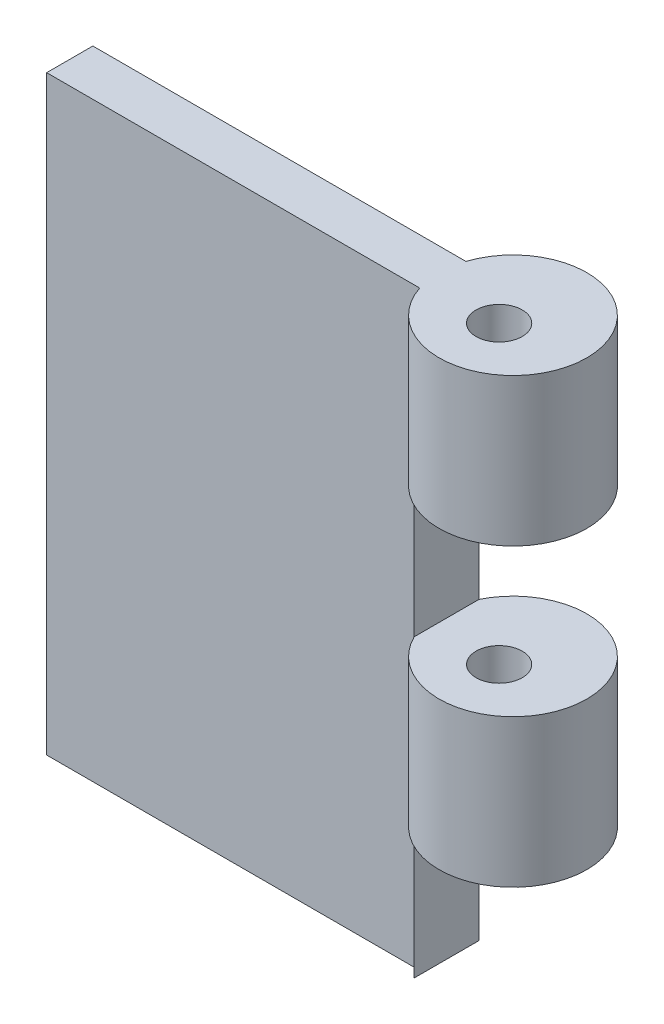
from build123d import *

# Parameters (mm, degrees)
SKETCH1_W                      = 15.24
SKETCH1_H                      = 20.32
BOSS_EXTRUDE1_DEPTH            = 1.5875
SKETCH2_W                      = 2.54
SKETCH2_H                      = 20.32
F_1_16_0_0625_DIAMETER_HOLE1_D = 1.5875
SKETCH10_W                     = 5.245479694
SKETCH10_H                     = 5.08
CUT_EXTRUDE1_DEPTH             = 6.35


with BuildPart() as part:
    # Sketch1 → Boss-Extrude1 (new body)
    with BuildSketch(Plane.XY):
        Rectangle(SKETCH1_W, SKETCH1_H)
    extrude(amount=BOSS_EXTRUDE1_DEPTH)

    # Sketch2 → Revolve-Thin1 (revolve)
    with BuildSketch(Plane(origin=(7.62, 0, 0), x_dir=(0, 0, -1), z_dir=(1, 0, 0))):
        with Locations((-2.06375, 0)):
            Rectangle(SKETCH2_W, SKETCH2_H)
    revolve(axis=Axis((7.62, -10.16, 0.79375), (0, 1, 0)))

    # 1/16 (0.0625) Diameter Hole1 (through all)
    with Locations(Plane(origin=(0, 10.16, 0), x_dir=(1, 0, 0), z_dir=(0, 1, 0))):
        with Locations((7.62, -1.27)):
            Hole(F_1_16_0_0625_DIAMETER_HOLE1_D / 2)

    # Sketch10 → Cut-Extrude1 (cut, symmetric)
    with BuildSketch(Plane.XY.offset(1.5875)):
        with Locations((7.960094746, 2.54)):
            Rectangle(SKETCH10_W, SKETCH10_H)
        with Locations((7.960094746, -7.62)):
            Rectangle(SKETCH10_W, SKETCH10_H)
    extrude(amount=CUT_EXTRUDE1_DEPTH, both=True, mode=Mode.SUBTRACT)


solid = part.part
